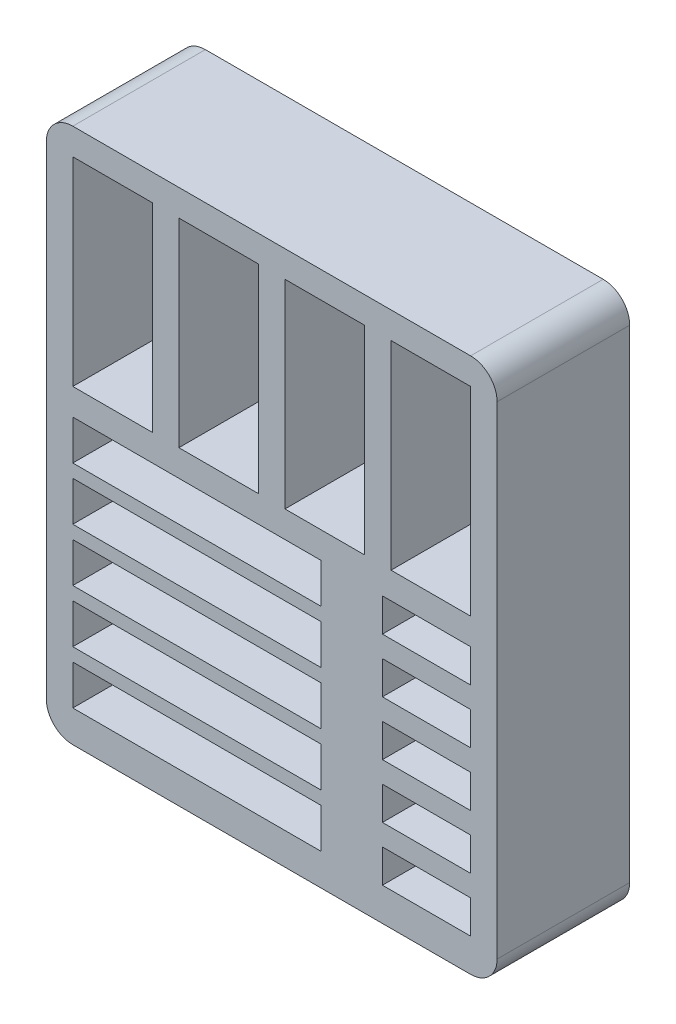
from build123d import *

# Parameters (mm, degrees)
BOSS_EXTRUDE1_DEPTH = 2
SKETCH1_3_W         = 37.4
SKETCH1_3_H         = 6
SKETCH1_3_W_2       = 13.3
SKETCH1_3_H_2       = 5
SKETCH1_3_W_3       = 12
SKETCH1_3_H_3       = 30
BOSS_EXTRUDE2_DEPTH = 20


with BuildPart() as part:
    # Sketch1 → Boss-Extrude1 (new body)
    with BuildSketch(Plane.XY):
        with BuildLine():
            Line((4, 0), (64, 0))
            ThreePointArc((64, 0), (66.828427125, 1.171572875), (68, 4))
            Line((68, 4), (68, 76.8))
            ThreePointArc((68, 76.8), (66.828427125, 79.628427125), (64, 80.8))
            Line((64, 80.8), (4, 80.8))
            ThreePointArc((4, 80.8), (1.171572875, 79.628427125), (0, 76.8))
            Line((0, 76.8), (0, 4))
            ThreePointArc((0, 4), (1.171572875, 1.171572875), (4, 0))
        make_face()
    extrude(amount=BOSS_EXTRUDE1_DEPTH)

    # Sketch1_3 → Boss-Extrude2 (add)
    with BuildSketch(Plane.XY):
        with BuildLine():
            ThreePointArc((0, 4), (1.171572875, 1.171572875), (4, 0))
            Line((4, 0), (64, 0))
            ThreePointArc((64, 0), (66.828427125, 1.171572875), (68, 4))
            Line((68, 4), (68, 76.8))
            ThreePointArc((68, 76.8), (66.828427125, 79.628427125), (64, 80.8))
            Line((64, 80.8), (4, 80.8))
            ThreePointArc((4, 80.8), (1.171572875, 79.628427125), (0, 76.8))
            Line((0, 76.8), (0, 4))
        make_face()
        with Locations((22.7, 7.8)):
            Rectangle(SKETCH1_3_W, SKETCH1_3_H, mode=Mode.SUBTRACT)
        with Locations((57.35, 7.5)):
            Rectangle(SKETCH1_3_W_2, SKETCH1_3_H_2, mode=Mode.SUBTRACT)
        with Locations((22.7, 15.8)):
            Rectangle(SKETCH1_3_W, SKETCH1_3_H, mode=Mode.SUBTRACT)
        with Locations((22.7, 23.8)):
            Rectangle(SKETCH1_3_W, SKETCH1_3_H, mode=Mode.SUBTRACT)
        with Locations((22.7, 31.8)):
            Rectangle(SKETCH1_3_W, SKETCH1_3_H, mode=Mode.SUBTRACT)
        with Locations((22.7, 39.8)):
            Rectangle(SKETCH1_3_W, SKETCH1_3_H, mode=Mode.SUBTRACT)
        with Locations((10, 61.8)):
            Rectangle(SKETCH1_3_W_3, SKETCH1_3_H_3, mode=Mode.SUBTRACT)
        with Locations((26, 61.8)):
            Rectangle(SKETCH1_3_W_3, SKETCH1_3_H_3, mode=Mode.SUBTRACT)
        with Locations((57.35, 15.7)):
            Rectangle(SKETCH1_3_W_2, SKETCH1_3_H_2, mode=Mode.SUBTRACT)
        with Locations((57.35, 32.1)):
            Rectangle(SKETCH1_3_W_2, SKETCH1_3_H_2, mode=Mode.SUBTRACT)
        with Locations((57.35, 23.9)):
            Rectangle(SKETCH1_3_W_2, SKETCH1_3_H_2, mode=Mode.SUBTRACT)
        with Locations((57.35, 40.3)):
            Rectangle(SKETCH1_3_W_2, SKETCH1_3_H_2, mode=Mode.SUBTRACT)
        with Locations((42, 61.8)):
            Rectangle(SKETCH1_3_W_3, SKETCH1_3_H_3, mode=Mode.SUBTRACT)
        with Locations((58, 61.8)):
            Rectangle(SKETCH1_3_W_3, SKETCH1_3_H_3, mode=Mode.SUBTRACT)
    extrude(amount=BOSS_EXTRUDE2_DEPTH)


solid = part.part
